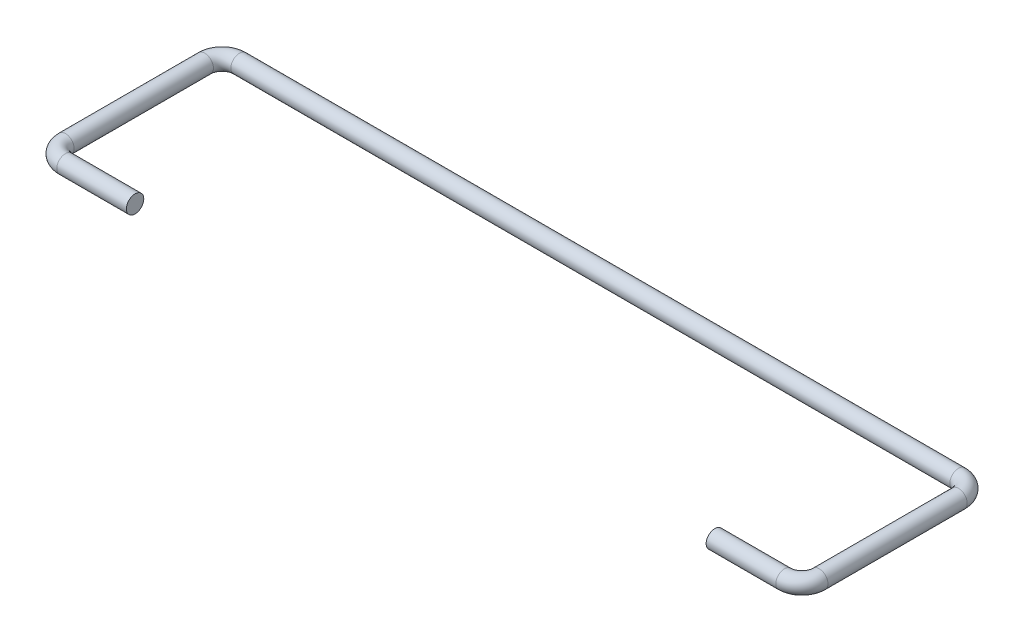
from build123d import *

# Parameters (mm, degrees)
SKETCH4_R = 1.27


with BuildPart() as part:
    # Sweep3: sweep along a path in Sketch2
    with BuildLine(Plane(origin=(0, 0, 0), x_dir=(1, 0, 0), z_dir=(0, 1, 0))) as sweep3_path:
        Line((-42.3, 0), (-52.46, 0))
        ThreePointArc((-52.46, 0), (-54.256051224, 0.743948776), (-55, 2.54))
        Line((-55, 2.54), (-55, 22.86))
        ThreePointArc((-55, 22.86), (-54.256051224, 24.656051224), (-52.46, 25.4))
        Line((-52.46, 25.4), (52.46, 25.4))
        ThreePointArc((52.46, 25.4), (54.256051224, 24.656051224), (55, 22.86))
        Line((55, 22.86), (55, 2.54))
        ThreePointArc((55, 2.54), (54.256051224, 0.743948776), (52.46, 0))
        Line((52.46, 0), (42.3, 0))
    # Sketch4 → Sweep3 (sweep)
    with BuildSketch(Plane(origin=(-42.3, 0, 0), x_dir=(0, 0, -1), z_dir=(1, 0, 0))):
        Circle(SKETCH4_R)
    sweep(path=sweep3_path.line)


solid = part.part
